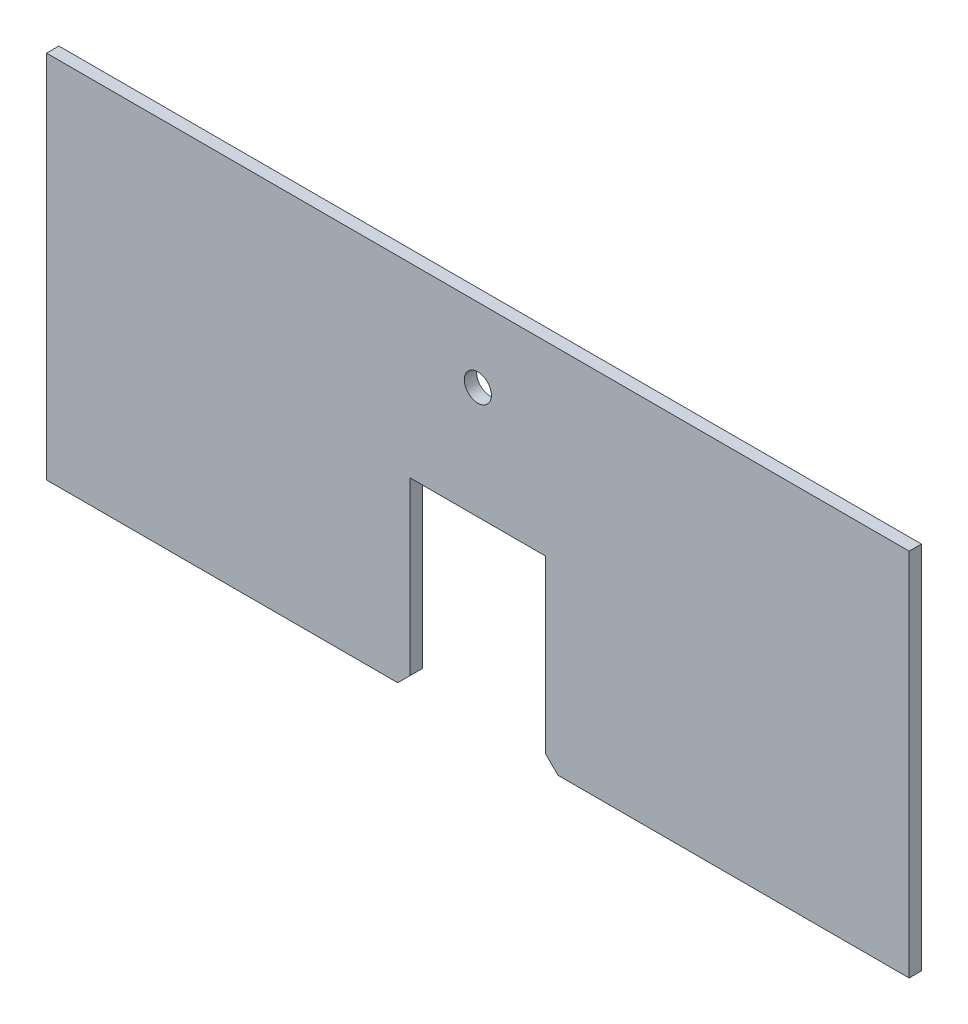
from build123d import *

# Parameters (mm, degrees)
BOSS_EXTRUDE1_DEPTH     = 5
SKETCH2_R               = 11
CUT_EXTRUDE1_DEPTH      = 6
CUT_EXTRUDE1_DEPTH_BACK = 6


with BuildPart() as part:
    # Sketch1 → Boss-Extrude1 (new body, symmetric)
    with BuildSketch(Plane.XY):
        Polygon((350, 232.421392473), (-350, 232.421392473), (-350, -67.578607527), (-65, -67.578607527), (-55, -57.578607527), (-55, 81.421392473), (55, 81.421392473), (55, -57.578607527), (65, -67.578607527), (350, -67.578607527), align=None)
    extrude(amount=BOSS_EXTRUDE1_DEPTH, both=True)

    # Sketch2 → Cut-Extrude1 (cut, two sides)
    with BuildSketch(Plane.XY) as cut_extrude1_sk:
        with Locations((0, 172.421392473)):
            Circle(SKETCH2_R)
    extrude(amount=CUT_EXTRUDE1_DEPTH, mode=Mode.SUBTRACT)
    extrude(cut_extrude1_sk.sketch, amount=-CUT_EXTRUDE1_DEPTH_BACK, mode=Mode.SUBTRACT)


solid = part.part
